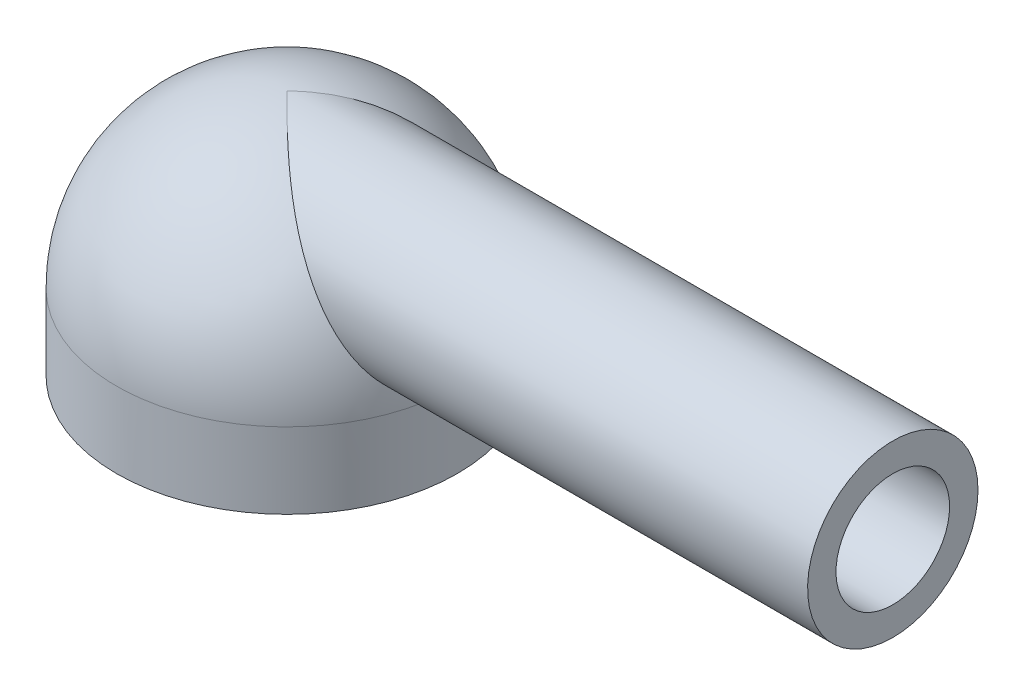
from build123d import *

# Parameters (mm, degrees)
SKETCH_1_R      = 2.25
SKETCH_1_R_2    = 1.75
EXTRUDE_1_DEPTH = 1
SKETCH_3_R      = 1.125
SKETCH_3_R_2    = 0.75
EXTRUDE_2_DEPTH = 8


with BuildPart() as part:
    # 草图1 → 凸台-拉伸1 (new body)
    with BuildSketch(Plane(origin=(0, 0, 0), x_dir=(1, 0, 0), z_dir=(0, 1, 0))):
        Circle(SKETCH_1_R)
        Circle(SKETCH_1_R_2, mode=Mode.SUBTRACT)
    extrude(amount=EXTRUDE_1_DEPTH)

    # 草图2 → 旋转1 (revolve)
    with BuildSketch(Plane(origin=(0, 0, 0), x_dir=(0, 0, -1), z_dir=(1, 0, 0))):
        with BuildLine():
            Line((0, 1), (0, 3.25))
            ThreePointArc((0, 3.25), (-1.590990258, 2.590990258), (-2.25, 1))
            Line((-2.25, 1), (0, 1))
        make_face()
    revolve(axis=Axis((0, 0, 0), (0, 1, 0)))

    # 草图3 → 凸台-拉伸2 (add)
    with BuildSketch(Plane(origin=(0, 0, 0), x_dir=(0, 0, -1), z_dir=(1, 0, 0))):
        with Locations((0, 2.125)):
            Circle(SKETCH_3_R)
        with Locations((0, 2.125)):
            Circle(SKETCH_3_R_2, mode=Mode.SUBTRACT)
    extrude(amount=EXTRUDE_2_DEPTH)


solid = part.part
